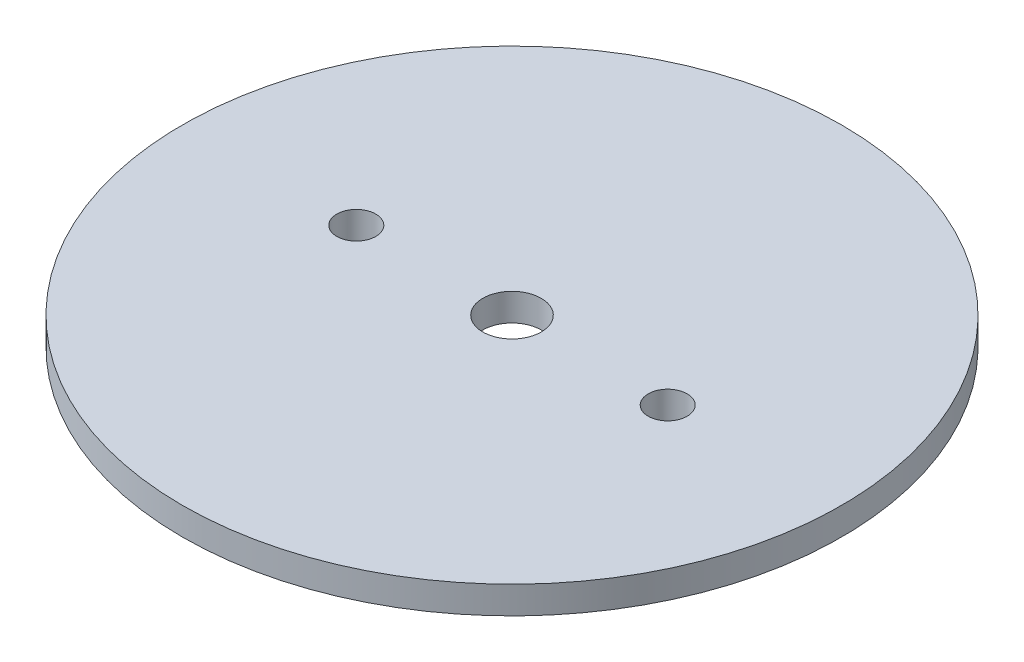
from build123d import *

# Parameters (mm, degrees)
SKETCH1_R            = 38.1
BOSS_EXTRUDE1_DEPTH  = 1.5875
M4_CLEARANCE_HOLE1_D = 4.5
SKETCH4_R            = 3.3782
CUT_EXTRUDE1_DEPTH   = 4.175


with BuildPart() as part:
    # Sketch1 → Boss-Extrude1 (new body, symmetric)
    with BuildSketch(Plane(origin=(0, 0, 0), x_dir=(1, 0, 0), z_dir=(0, 1, 0))):
        Circle(SKETCH1_R)
    extrude(amount=BOSS_EXTRUDE1_DEPTH, both=True)

    # M4 Clearance Hole1 (through all)
    with Locations(Plane(origin=(0, -1.5875, 0), x_dir=(-1, 0, 0), z_dir=(0, -1, 0))):
        with Locations((-18, 0), (18, 0)):
            Hole(M4_CLEARANCE_HOLE1_D / 2)

    # Sketch4 → Cut-Extrude1 (cut, through all)
    with BuildSketch(Plane.XZ.offset(1.5875)):
        Circle(SKETCH4_R)
    extrude(amount=-CUT_EXTRUDE1_DEPTH, mode=Mode.SUBTRACT)


solid = part.part
